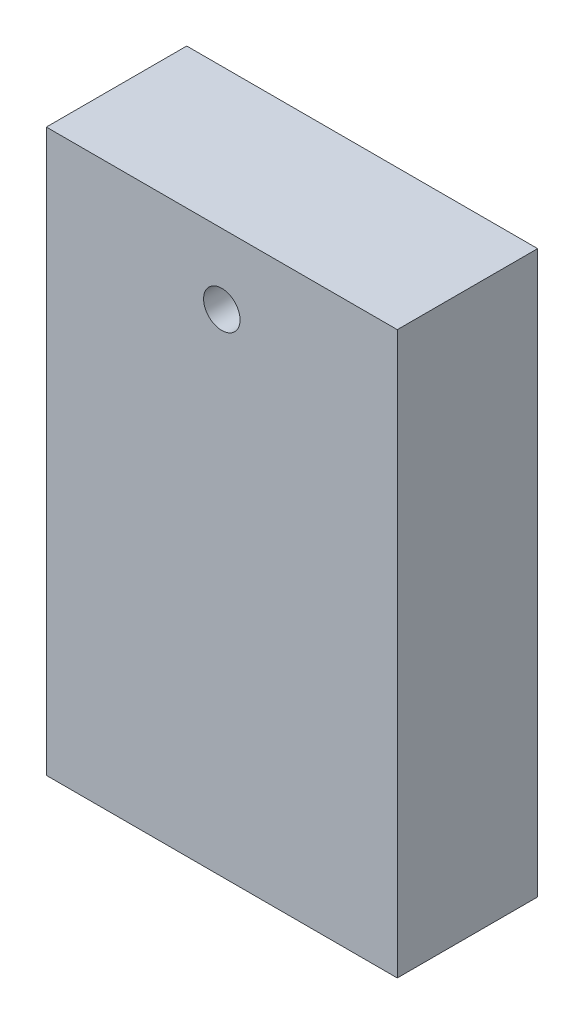
from build123d import *

# Parameters (mm, degrees)
SKETCH1_W           = 25
SKETCH1_H           = 40
SKETCH1_R           = 1.3
BOSS_EXTRUDE1_DEPTH = 10


with BuildPart() as part:
    # Sketch1 → Boss-Extrude1 (new body)
    with BuildSketch(Plane.XY):
        Rectangle(SKETCH1_W, SKETCH1_H)
        with Locations((0, 15)):
            Circle(SKETCH1_R, mode=Mode.SUBTRACT)
    extrude(amount=BOSS_EXTRUDE1_DEPTH)


solid = part.part
